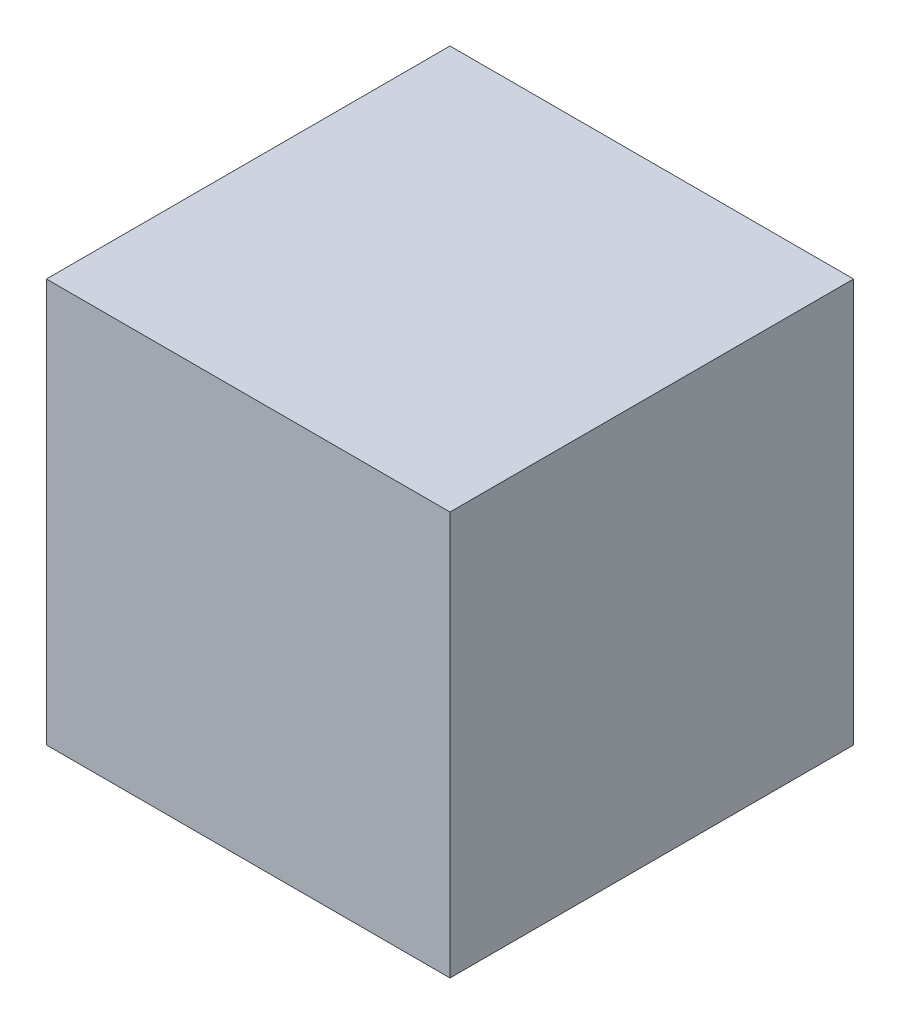
from build123d import *

# Parameters (mm, degrees)
SKETCH1_W           = 50
SKETCH1_H           = 50
BOSS_EXTRUDE1_DEPTH = 50


with BuildPart() as part:
    # Sketch1 → Boss-Extrude1 (new body)
    with BuildSketch(Plane(origin=(0, 0, 0), x_dir=(1, 0, 0), z_dir=(0, 1, 0))):
        with Locations((25, 25)):
            Rectangle(SKETCH1_W, SKETCH1_H)
    extrude(amount=BOSS_EXTRUDE1_DEPTH)


solid = part.part
